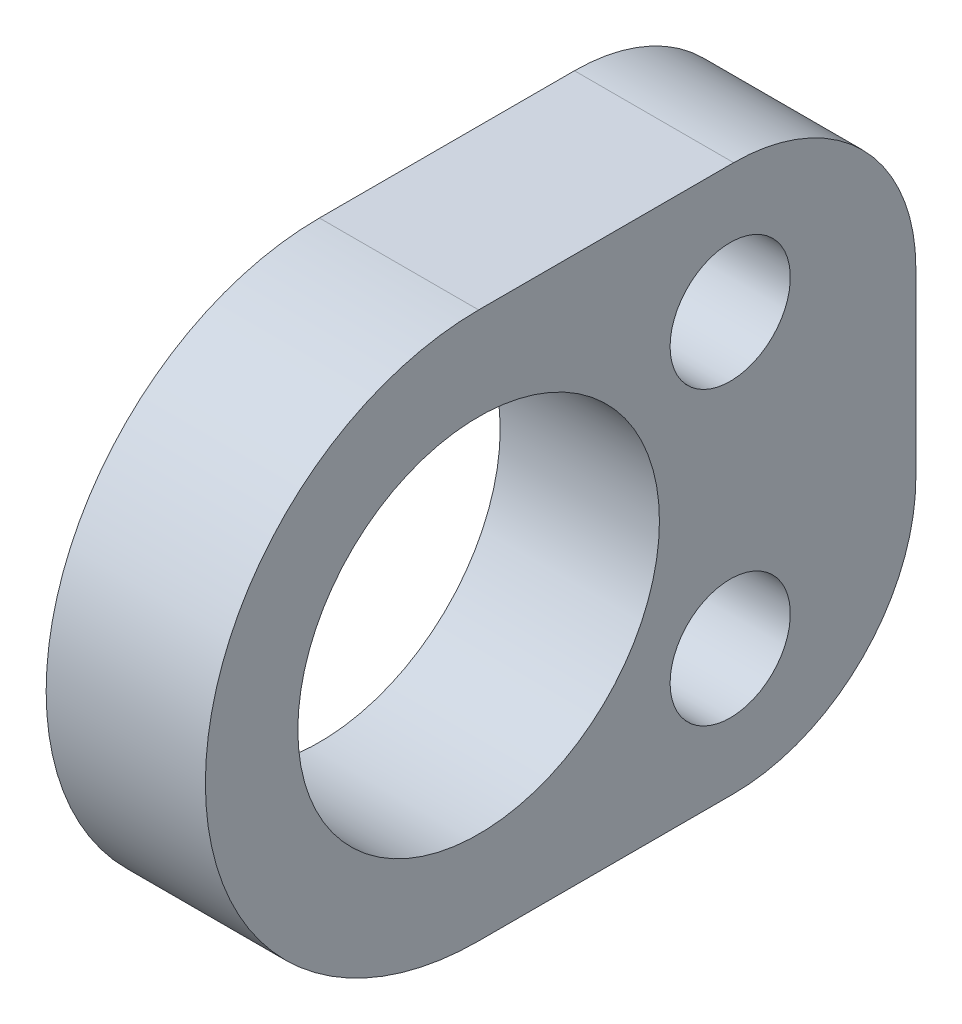
from build123d import *

# Parameters (mm, degrees)
SKETCH1_R           = 4.9625
BOSS_EXTRUDE1_DEPTH = 4.37
FILLET1_R           = 5
SKETCH2_R           = 1.65
CUT_EXTRUDE1_DEPTH  = 5.37


with BuildPart() as part:
    # Sketch1 → Boss-Extrude1 (new body)
    with BuildSketch(Plane(origin=(0, 0, 0), x_dir=(0, 0, -1), z_dir=(1, 0, 0))):
        with BuildLine():
            Line((0, 7.5), (12, 7.5))
            Line((12, 7.5), (12, -7.5))
            Line((12, -7.5), (0, -7.5))
            ThreePointArc((0, -7.5), (-7.5, 0), (0, 7.5))
        make_face()
        Circle(SKETCH1_R, mode=Mode.SUBTRACT)
    extrude(amount=BOSS_EXTRUDE1_DEPTH)

    # Fillet1
    fillet1_edges = [part.edges().sort_by_distance(p)[0] for p in [
        (2.185, -7.5, -12),
        (2.185, 7.5, -12),
    ]]
    fillet(fillet1_edges, radius=FILLET1_R)

    # Sketch2 → Cut-Extrude1 (cut, through all)
    with BuildSketch(Plane.ZY):
        with Locations((-6.905099565, 4)):
            Circle(SKETCH2_R)
        with Locations((-6.905099565, -4)):
            Circle(SKETCH2_R)
    extrude(amount=-CUT_EXTRUDE1_DEPTH, mode=Mode.SUBTRACT)


solid = part.part
